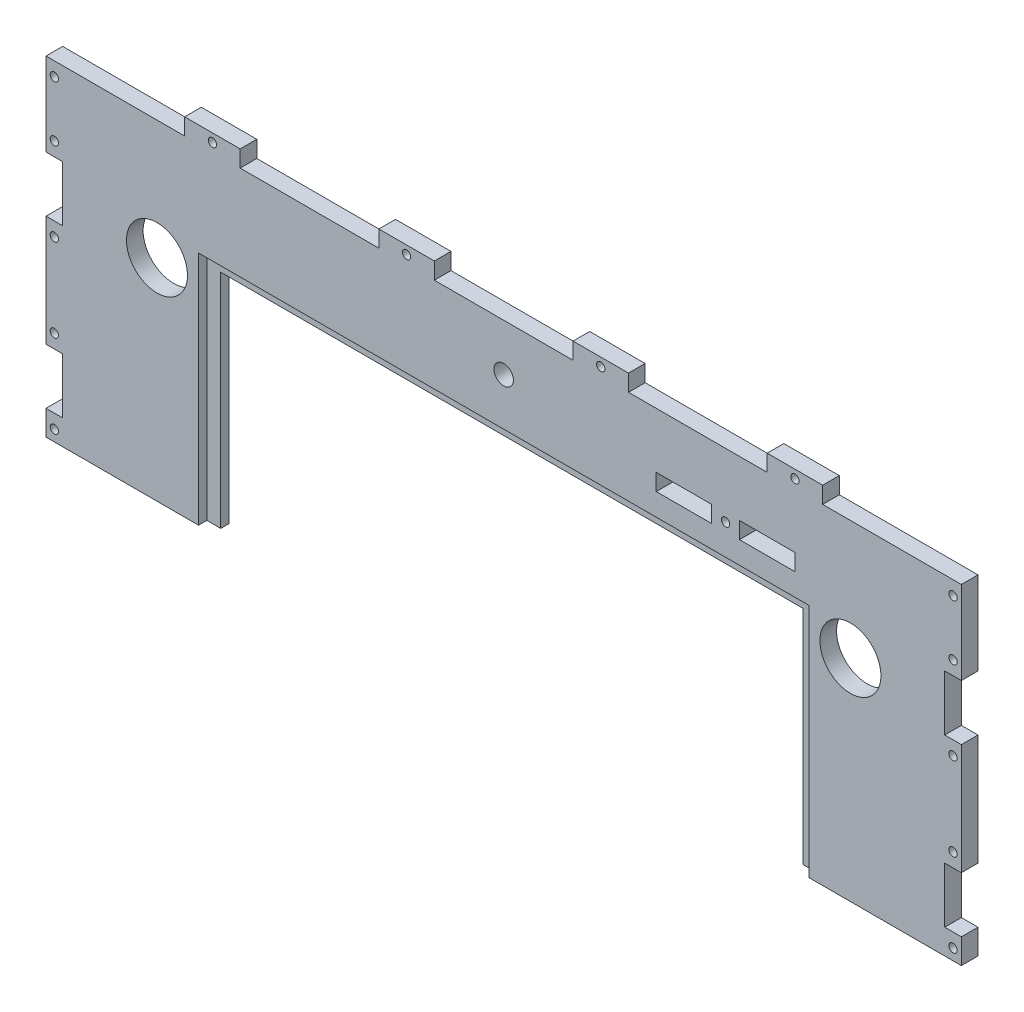
from build123d import *

# Parameters (mm, degrees)
ESQUISSE1_W                  = 330
ESQUISSE1_H                  = 238
ESQUISSE1_R                  = 11
ESQUISSE1_W_2                = 15
ESQUISSE1_H_2                = 6
ESQUISSE1_W_3                = 20
BOSS_EXTRU_1_DEPTH           = 6
ESQUISSE2_W                  = 20
ESQUISSE2_H                  = 6
BOSS_EXTRU_2_DEPTH           = 6
ESQUISSE3_W                  = 6
ESQUISSE3_H                  = 20
ESQUISSE3_W_2                = 12
ESQUISSE3_H_2                = 10
ENL_V_MAT_EXTRU_1_DEPTH      = 6
ESQUISSE4_R                  = 1.5
ENL_V_MAT_EXTRU_2_DEPTH      = 6
ESQUISSE5_W                  = 423.604058921
ESQUISSE5_H                  = 150.356061945
ENL_V_MAT_EXTRU_3_DEPTH      = 6
ESQUISSE6_W                  = 1.709615384
ESQUISSE6_H                  = 19.05
ESQUISSE6_W_2                = 1.709615385
ENL_V_MAT_EXTRU_4_DEPTH      = 6
ESQUISSE7_W                  = 1.58262541
ESQUISSE7_H                  = 1.953846154
ESQUISSE7_W_2                = 1.587980571
ESQUISSE7_H_2                = 1.936817114
ESQUISSE7_W_3                = 0.906225897
ESQUISSE7_W_4                = 1.709615385
ESQUISSE7_H_3                = 0.97063598
ESQUISSE7_W_5                = 1.216684544
ESQUISSE7_W_6                = 1.709615384
ESQUISSE7_H_4                = 3.052884616
ESQUISSE7_H_5                = 2.641773465
ESQUISSE7_W_7                = 1.710749653
ESQUISSE7_H_6                = 0.906659764
ESQUISSE7_W_8                = 1.70801118
ESQUISSE7_H_7                = 1.10546444
BOSS_EXTRU_5_DEPTH           = 6
ESQUISSE8_W                  = 210
ESQUISSE8_H                  = 80
ENL_V_MAT_EXTRU_5_DEPTH      = 6
ENL_V_MAT_EXTRU_7_DEPTH      = 1
ENL_V_MAT_EXTRU_7_DEPTH_BACK = 3
ESQUISSE12_R                 = 3.5
ENL_V_MAT_EXTRU_8_DEPTH      = 10


with BuildPart() as part:
    # Esquisse1 → Boss.-Extru.1 (new body)
    with BuildSketch(Plane.XY):
        Rectangle(ESQUISSE1_W, ESQUISSE1_H)
        with Locations((-125, 76)):
            Circle(ESQUISSE1_R, mode=Mode.SUBTRACT)
        with Locations((125, 76)):
            Circle(ESQUISSE1_R, mode=Mode.SUBTRACT)
        with Locations((-85, -58)):
            Rectangle(ESQUISSE1_W_2, ESQUISSE1_H_2, mode=Mode.SUBTRACT)
        with Locations((0, -58)):
            Rectangle(ESQUISSE1_W_2, ESQUISSE1_H_2, mode=Mode.SUBTRACT)
        with Locations((85, -58)):
            Rectangle(ESQUISSE1_W_2, ESQUISSE1_H_2, mode=Mode.SUBTRACT)
        with Locations((65, 96)):
            Rectangle(ESQUISSE1_W_3, ESQUISSE1_H_2, mode=Mode.SUBTRACT)
        with Locations((95, 96)):
            Rectangle(ESQUISSE1_W_3, ESQUISSE1_H_2, mode=Mode.SUBTRACT)
    extrude(amount=BOSS_EXTRU_1_DEPTH)

    # Esquisse2 → Boss.-Extru.2 (add)
    with BuildSketch(Plane.XY.offset(6)):
        with Locations((-105, 122)):
            Rectangle(ESQUISSE2_W, ESQUISSE2_H)
        with Locations((-35, 122)):
            Rectangle(ESQUISSE2_W, ESQUISSE2_H)
        with Locations((35, 122)):
            Rectangle(ESQUISSE2_W, ESQUISSE2_H)
        with Locations((105, 122)):
            Rectangle(ESQUISSE2_W, ESQUISSE2_H)
        with Locations((105, -122)):
            Rectangle(ESQUISSE2_W, ESQUISSE2_H)
        with Locations((35, -122)):
            Rectangle(ESQUISSE2_W, ESQUISSE2_H)
        with Locations((-35, -122)):
            Rectangle(ESQUISSE2_W, ESQUISSE2_H)
        with Locations((-105, -122)):
            Rectangle(ESQUISSE2_W, ESQUISSE2_H)
    extrude(amount=-BOSS_EXTRU_2_DEPTH)

    # Esquisse3 → Enlèv. mat.-Extru.1 (cut)
    with BuildSketch(Plane.XY.offset(6)):
        with Locations((-162, 79)):
            Rectangle(ESQUISSE3_W, ESQUISSE3_H)
        with Locations((-162, 19)):
            Rectangle(ESQUISSE3_W, ESQUISSE3_H)
        with Locations((-162, -19)):
            Rectangle(ESQUISSE3_W, ESQUISSE3_H)
        with Locations((-162, -79)):
            Rectangle(ESQUISSE3_W, ESQUISSE3_H)
        with Locations((162, -79)):
            Rectangle(ESQUISSE3_W, ESQUISSE3_H)
        with Locations((162, -19)):
            Rectangle(ESQUISSE3_W, ESQUISSE3_H)
        with Locations((162, 19)):
            Rectangle(ESQUISSE3_W, ESQUISSE3_H)
        with Locations((162, 79)):
            Rectangle(ESQUISSE3_W, ESQUISSE3_H)
        with Locations((159, -114)):
            Rectangle(ESQUISSE3_W_2, ESQUISSE3_H_2)
        with Locations((-159, -114)):
            Rectangle(ESQUISSE3_W_2, ESQUISSE3_H_2)
    extrude(amount=-ENL_V_MAT_EXTRU_1_DEPTH, mode=Mode.SUBTRACT)

    # Esquisse4 → Enlèv. mat.-Extru.2 (cut)
    with BuildSketch(Plane.XY.offset(6)):
        with Locations((-162, 114)):
            Circle(ESQUISSE4_R)
        with Locations((-162, 94)):
            Circle(ESQUISSE4_R)
        with Locations((-162, 64)):
            Circle(ESQUISSE4_R)
        with Locations((-162, 34)):
            Circle(ESQUISSE4_R)
        with Locations((-162, 4)):
            Circle(ESQUISSE4_R)
        with Locations((-105, 122)):
            Circle(ESQUISSE4_R)
        with Locations((-162, -4)):
            Circle(ESQUISSE4_R)
        with Locations((-162, -34)):
            Circle(ESQUISSE4_R)
        with Locations((-162, -64)):
            Circle(ESQUISSE4_R)
        with Locations((-162, -94)):
            Circle(ESQUISSE4_R)
        with Locations((-97.5, -58)):
            Circle(ESQUISSE4_R)
        with Locations((-72.5, -58)):
            Circle(ESQUISSE4_R)
        with Locations((162, -94)):
            Circle(ESQUISSE4_R)
        with Locations((162, -64)):
            Circle(ESQUISSE4_R)
        with Locations((162, -34)):
            Circle(ESQUISSE4_R)
        with Locations((162, -4)):
            Circle(ESQUISSE4_R)
        with Locations((80, 96)):
            Circle(ESQUISSE4_R)
        with Locations((162, 4)):
            Circle(ESQUISSE4_R)
        with Locations((162, 34)):
            Circle(ESQUISSE4_R)
        with Locations((162, 64)):
            Circle(ESQUISSE4_R)
        with Locations((162, 94)):
            Circle(ESQUISSE4_R)
        with Locations((162, 114)):
            Circle(ESQUISSE4_R)
        with Locations((-12.5, -58)):
            Circle(ESQUISSE4_R)
        with Locations((12.5, -58)):
            Circle(ESQUISSE4_R)
        with Locations((72.5, -58)):
            Circle(ESQUISSE4_R)
        with Locations((97.5, -58)):
            Circle(ESQUISSE4_R)
        with Locations((-35, 122)):
            Circle(ESQUISSE4_R)
        with Locations((35, 122)):
            Circle(ESQUISSE4_R)
        with Locations((105, 122)):
            Circle(ESQUISSE4_R)
    extrude(amount=-ENL_V_MAT_EXTRU_2_DEPTH, mode=Mode.SUBTRACT)

    # Esquisse5 → Enlèv. mat.-Extru.3 (cut)
    with BuildSketch(Plane.XY.offset(6)):
        with Locations((11.705214191, -75.178030973)):
            Rectangle(ESQUISSE5_W, ESQUISSE5_H)
    extrude(amount=-ENL_V_MAT_EXTRU_3_DEPTH, mode=Mode.SUBTRACT)

    # Esquisse6 → Enlèv. mat.-Extru.4 (cut)
    with BuildSketch(Plane.XY.offset(6)):
        with BuildLine():
            Line((-81.011538462, 33.174909856), (-79.401141827, 34.140384615))
            add(Edge.make_bspline(
                [(-79.401141827, 34.140384615), (-79.251363993, 33.889662749), (-78.964395442, 33.409289328), (-78.485688759, 32.760184851), (-77.989665343, 32.208485112), (-77.47265197, 31.757399576), (-76.937804452, 31.402259207), (-76.381631246, 31.15078706), (-75.80600659, 30.993945823), (-75.414263362, 30.974895352), (-75.218689904, 30.965384615)],
                knots=[0, 0, 0, 0, 0.000875761, 0.001677924, 0.002415421, 0.003097148, 0.00373115, 0.004334059, 0.004921814, 0.005507782, 0.005507782, 0.005507782, 0.005507782], degree=3))
            add(Edge.make_bspline(
                [(-75.218689904, 30.965384615), (-75.051665706, 30.970036476), (-74.720539841, 30.9792588), (-74.233065347, 31.06787288), (-73.759635824, 31.204010324), (-73.31000881, 31.398978537), (-72.890388393, 31.634863724), (-72.522414809, 31.91977649), (-72.204300964, 32.238761695), (-71.944082784, 32.594630144), (-71.744438591, 32.977356339), (-71.59099319, 33.370199731), (-71.50583929, 33.77933151), (-71.493011817, 34.054797029), (-71.486538462, 34.193810096)],
                knots=[0, 0, 0, 0, 0.000500623, 0.000992486, 0.001481559, 0.001975623, 0.002459366, 0.002921918, 0.003367162, 0.003806809, 0.004238704, 0.004658996, 0.005068388, 0.005485462, 0.005485462, 0.005485462, 0.005485462], degree=3))
            add(Edge.make_bspline(
                [(-71.486538462, 34.193810096), (-71.494562924, 34.352419578), (-71.510875484, 34.674849478), (-71.648751111, 35.150553303), (-71.865644869, 35.621320006), (-72.065738687, 35.912519751), (-72.169621394, 36.063701923)],
                knots=[0, 0, 0, 0, 0.000475055, 0.000965718, 0.001474521, 0.002023895, 0.002023895, 0.002023895, 0.002023895], degree=3))
            add(Edge.make_bspline(
                [(-72.169621394, 36.063701923), (-72.254914309, 36.17281392), (-72.433976113, 36.401880909), (-72.741810575, 36.742849977), (-73.103031854, 37.0945588), (-73.505278346, 37.470437381), (-73.963202729, 37.853003818), (-74.462462486, 38.260501159), (-75.015804347, 38.6774326), (-75.403877322, 38.957046135), (-75.604116587, 39.101322115)],
                knots=[0, 0, 0, 0, 0.000415395, 0.00087207, 0.001376677, 0.001927572, 0.002523203, 0.00316627, 0.003860812, 0.004601225, 0.004601225, 0.004601225, 0.004601225], degree=3))
            add(Edge.make_bspline(
                [(-75.604116587, 39.101322115), (-75.804544337, 39.244080571), (-76.187746934, 39.517023867), (-76.723642932, 39.922104613), (-77.202856367, 40.292457674), (-77.623257299, 40.631569511), (-77.984660819, 40.939486117), (-78.289914814, 41.213250614), (-78.531243246, 41.460266853), (-78.665440049, 41.62051187), (-78.725691106, 41.692457933)],
                knots=[0, 0, 0, 0, 0.000738177, 0.001411339, 0.002015128, 0.00255509, 0.003031508, 0.003439403, 0.00378484, 0.004066302, 0.004066302, 0.004066302, 0.004066302], degree=3))
            add(Edge.make_bspline(
                [(-78.725691106, 41.692457933), (-78.809905959, 41.804586433), (-78.97552577, 42.025102178), (-79.1941436, 42.369770333), (-79.379958186, 42.722594106), (-79.525621737, 43.084521597), (-79.648283157, 43.45047171), (-79.730785608, 43.825219204), (-79.782445925, 44.207082542), (-79.787736309, 44.464058881), (-79.790384615, 44.592698317)],
                knots=[0, 0, 0, 0, 0.000420569, 0.000827105, 0.001223098, 0.001614988, 0.001996332, 0.002379618, 0.002764439, 0.003150168, 0.003150168, 0.003150168, 0.003150168], degree=3))
            add(Edge.make_bspline(
                [(-79.790384615, 44.592698317), (-79.783280549, 44.79424609), (-79.769224262, 45.193033694), (-79.650349446, 45.775587214), (-79.462718411, 46.331773285), (-79.199856235, 46.85608553), (-78.860998357, 47.334871798), (-78.468862411, 47.773639491), (-78.00180275, 48.142494203), (-77.489343472, 48.464776978), (-76.928422361, 48.717031228), (-76.340643301, 48.907318848), (-75.725072095, 49.015137808), (-75.308132177, 49.030610571), (-75.096574519, 49.038461538)],
                knots=[0, 0, 0, 0, 0.000604151, 0.001195389, 0.001775851, 0.002361222, 0.002947712, 0.003531189, 0.004120021, 0.004726782, 0.005343269, 0.00595998, 0.006576078, 0.0072107, 0.0072107, 0.0072107, 0.0072107], degree=3))
            add(Edge.make_bspline(
                [(-75.096574519, 49.038461538), (-74.872088773, 49.030718793), (-74.425658273, 49.015320944), (-73.768981828, 48.881440095), (-73.136735643, 48.659912153), (-72.628137302, 48.408513886), (-72.230086129, 48.157427181), (-71.926523112, 47.92871928), (-71.618906702, 47.665420475), (-71.304755575, 47.366829435), (-70.989392843, 47.030206404), (-70.668136624, 46.657856798), (-70.340235675, 46.252056115), (-70.129293065, 45.962362761), (-70.021153846, 45.813852163)],
                knots=[0, 0, 0, 0, 0.000672945, 0.001338273, 0.002000837, 0.002678365, 0.003035146, 0.003411415, 0.003817467, 0.004249345, 0.004710968, 0.005200635, 0.005724499, 0.006275553, 0.006275553, 0.006275553, 0.006275553], degree=3))
            Line((-70.021153846, 45.813852163), (-71.566676683, 44.642307692))
            add(Edge.make_bspline(
                [(-71.566676683, 44.642307692), (-71.659999544, 44.762533279), (-71.839717554, 44.994059648), (-72.11256519, 45.318297809), (-72.369732831, 45.614478933), (-72.623100007, 45.871736273), (-72.859285344, 46.104157885), (-73.088522388, 46.303147418), (-73.307512214, 46.470654588), (-73.583557113, 46.649417392), (-73.930363552, 46.82661779), (-74.365707956, 46.976563487), (-74.82065611, 47.066670324), (-75.130515962, 47.078584126), (-75.287379808, 47.084615385)],
                knots=[0, 0, 0, 0, 0.000456531, 0.000879173, 0.001271193, 0.001632818, 0.001962066, 0.002265056, 0.002542873, 0.002788442, 0.003250947, 0.003707127, 0.004165902, 0.004636274, 0.004636274, 0.004636274, 0.004636274], degree=3))
            add(Edge.make_bspline(
                [(-75.287379808, 47.084615385), (-75.484174594, 47.078020275), (-75.863674801, 47.065302227), (-76.402464514, 46.926400593), (-76.887390021, 46.707696467), (-77.304054696, 46.401182087), (-77.650965957, 46.038029255), (-77.901911383, 45.620132915), (-78.052951564, 45.15867441), (-78.0713826, 44.836774823), (-78.080769231, 44.672836538)],
                knots=[0, 0, 0, 0, 0.000589178, 0.001136173, 0.001656971, 0.002176017, 0.002678179, 0.00315397, 0.003627044, 0.004118018, 0.004118018, 0.004118018, 0.004118018], degree=3))
            add(Edge.make_bspline(
                [(-78.080769231, 44.672836538), (-78.078629499, 44.57077492), (-78.074346536, 44.366484791), (-78.01461228, 44.064670623), (-77.937871646, 43.763618904), (-77.816263893, 43.464683132), (-77.648377312, 43.162635263), (-77.427913426, 42.852274092), (-77.150255256, 42.530864077), (-76.937564661, 42.321818229), (-76.825270433, 42.211448317)],
                knots=[0, 0, 0, 0, 0.00030567, 0.000611839, 0.000920095, 0.001236855, 0.001576745, 0.001954713, 0.002376906, 0.002849133, 0.002849133, 0.002849133, 0.002849133], degree=3))
            add(Edge.make_bspline(
                [(-76.825270433, 42.211448317), (-76.783570677, 42.174235363), (-76.684501603, 42.0858259), (-76.503385493, 41.941087915), (-76.26421112, 41.762547112), (-75.973223996, 41.541636147), (-75.625058785, 41.285378474), (-75.2196772, 40.997050671), (-74.761598, 40.667292672), (-74.436540144, 40.43674663), (-74.264663462, 40.31484375)],
                knots=[0, 0, 0, 0, 0.000167648, 0.000398294, 0.000695191, 0.001063064, 0.001494301, 0.001992036, 0.002555426, 0.003187576, 0.003187576, 0.003187576, 0.003187576], degree=3))
            add(Edge.make_bspline(
                [(-74.264663462, 40.31484375), (-74.057911562, 40.164395779), (-73.657565164, 39.873074134), (-73.087928907, 39.435383076), (-72.571435466, 39.007314507), (-72.106271458, 38.591602102), (-71.687841428, 38.191399196), (-71.320787548, 37.801891029), (-71.001369774, 37.425868126), (-70.657494313, 36.94378025), (-70.306115324, 36.351700348), (-70.004355119, 35.626285936), (-69.814081828, 34.898051677), (-69.789199723, 34.408592753), (-69.776923077, 34.167097356)],
                knots=[0, 0, 0, 0, 0.000767075, 0.001485335, 0.002154722, 0.002779037, 0.003356594, 0.003891122, 0.004384123, 0.00483528, 0.005666491, 0.006443216, 0.007186426, 0.00791025, 0.00791025, 0.00791025, 0.00791025], degree=3))
            add(Edge.make_bspline(
                [(-69.776923077, 34.167097356), (-69.780499786, 33.996309397), (-69.787583746, 33.658050067), (-69.869013863, 33.16136172), (-69.988319469, 32.678956558), (-70.168136414, 32.216797503), (-70.387609604, 31.76642958), (-70.666100181, 31.339666579), (-70.988903437, 30.927063181), (-71.3592015, 30.539621607), (-71.764399911, 30.183951597), (-72.192664021, 29.86756342), (-72.644694792, 29.60375726), (-73.11804003, 29.388487677), (-73.612808463, 29.22012096), (-74.128833686, 29.098130915), (-74.666966312, 29.023260545), (-75.032728933, 29.015489444), (-75.218689904, 29.011538462)],
                knots=[0, 0, 0, 0, 0.000511871, 0.001013801, 0.001506197, 0.002000187, 0.002498522, 0.003006623, 0.003525739, 0.004068285, 0.004611795, 0.005141506, 0.005663141, 0.00617888, 0.006699006, 0.007228455, 0.007767608, 0.008325229, 0.008325229, 0.008325229, 0.008325229], degree=3))
            add(Edge.make_bspline(
                [(-75.218689904, 29.011538462), (-75.362573699, 29.01432075), (-75.648529222, 29.019850287), (-76.07149083, 29.068734113), (-76.485907737, 29.137897063), (-76.886579758, 29.247701643), (-77.278669098, 29.380926333), (-77.660470475, 29.544964972), (-78.032168925, 29.741545739), (-78.395847483, 29.966308659), (-78.750581205, 30.227880098), (-79.093042881, 30.532535842), (-79.434468876, 30.87187352), (-79.764781705, 31.255108157), (-80.090662676, 31.676048294), (-80.40568659, 32.138632278), (-80.716374225, 32.640340446), (-80.9113127, 32.993391841), (-81.011538462, 33.174909856)],
                knots=[0, 0, 0, 0, 0.00043149, 0.000857546, 0.001276015, 0.001690708, 0.002102228, 0.002517623, 0.002935831, 0.003362587, 0.00379916, 0.004256154, 0.004736468, 0.005242286, 0.005772779, 0.00633272, 0.006920475, 0.007542442, 0.007542442, 0.007542442, 0.007542442], degree=3))
        make_face()
        with BuildLine():
            Line((-65.869230769, 48.55), (-64.159615385, 48.55))
            Line((-64.159615385, 48.55), (-64.159615385, 37.136027644))
            add(Edge.make_bspline(
                [(-64.159615385, 37.136027644), (-64.159869805, 36.97447964), (-64.160352613, 36.667914462), (-64.157127644, 36.231569854), (-64.148095939, 35.843644041), (-64.142401842, 35.502641707), (-64.129734498, 35.21012761), (-64.1194037, 34.96451699), (-64.106120098, 34.766972831), (-64.090155559, 34.651688077), (-64.083293269, 34.602133413)],
                knots=[0, 0, 0, 0, 0.000484645, 0.000919698, 0.001309016, 0.001648735, 0.001942798, 0.002187297, 0.002386321, 0.002536367, 0.002536367, 0.002536367, 0.002536367], degree=3))
            add(Edge.make_bspline(
                [(-64.083293269, 34.602133413), (-64.055113101, 34.423353173), (-64.000340615, 34.075866319), (-63.860751044, 33.581065527), (-63.665801503, 33.135124305), (-63.434790085, 32.724127134), (-63.130356872, 32.359513618), (-62.765666201, 32.023625907), (-62.323827204, 31.729865085), (-61.832551622, 31.461255666), (-61.303041972, 31.245364289), (-60.761960651, 31.082114692), (-60.217441007, 30.982625252), (-59.852899308, 30.971105233), (-59.671875, 30.965384615)],
                knots=[0, 0, 0, 0, 0.000542706, 0.001054833, 0.001536872, 0.002000273, 0.002463973, 0.002955555, 0.003482676, 0.004051288, 0.004633103, 0.005194538, 0.005744759, 0.006287505, 0.006287505, 0.006287505, 0.006287505], degree=3))
            add(Edge.make_bspline(
                [(-59.671875, 30.965384615), (-59.51646107, 30.971229429), (-59.20653084, 30.982885298), (-58.746030125, 31.055065373), (-58.297538105, 31.185152738), (-57.858840118, 31.353009137), (-57.447626903, 31.574792454), (-57.063669026, 31.830992309), (-56.720965327, 32.13149722), (-56.408229653, 32.464057667), (-56.135896645, 32.839287149), (-55.899833717, 33.249015301), (-55.706471157, 33.699408174), (-55.610984258, 34.015934387), (-55.561929087, 34.178545673)],
                knots=[0, 0, 0, 0, 0.000466331, 0.000929968, 0.001393872, 0.001865126, 0.002336303, 0.002792484, 0.003246969, 0.003700588, 0.004159315, 0.004634539, 0.005116578, 0.005625853, 0.005625853, 0.005625853, 0.005625853], degree=3))
            add(Edge.make_bspline(
                [(-55.561929087, 34.178545673), (-55.545599833, 34.245757199), (-55.509211676, 34.395531565), (-55.475209903, 34.648740304), (-55.439795814, 34.947495271), (-55.415223655, 35.293942995), (-55.391268441, 35.686922574), (-55.376937002, 36.128481204), (-55.370312865, 36.617015519), (-55.368338848, 36.957940643), (-55.367307692, 37.136027644)],
                knots=[0, 0, 0, 0, 0.000207373, 0.000462111, 0.000765533, 0.00111002, 0.001503745, 0.001946676, 0.002435197, 0.002969466, 0.002969466, 0.002969466, 0.002969466], degree=3))
            Line((-55.367307692, 37.136027644), (-55.367307692, 48.55))
            Line((-55.367307692, 48.55), (-53.657692308, 48.55))
            Line((-53.657692308, 48.55), (-53.657692308, 37.044441106))
            add(Edge.make_bspline(
                [(-53.657692308, 37.044441106), (-53.659075449, 36.837077072), (-53.661774732, 36.432393552), (-53.685182156, 35.839386869), (-53.722503826, 35.276851356), (-53.775234705, 34.744711397), (-53.84510468, 34.244871187), (-53.922802666, 33.77294952), (-54.021751267, 33.332333946), (-54.137321636, 32.91958893), (-54.269439091, 32.526693493), (-54.440568769, 32.15381089), (-54.633379262, 31.789605372), (-54.862059016, 31.439585522), (-55.119023827, 31.102201569), (-55.409953689, 30.779499603), (-55.725226622, 30.466322794), (-56.070083654, 30.170704534), (-56.438840084, 29.899603022), (-56.830398996, 29.66121801), (-57.241752557, 29.45970375), (-57.671831487, 29.293827647), (-58.12081932, 29.169106757), (-58.588727377, 29.076169123), (-59.076620701, 29.023360904), (-59.408442616, 29.015512684), (-59.576472356, 29.011538462)],
                knots=[0, 0, 0, 0, 0.000622072, 0.001214011, 0.001780083, 0.002313205, 0.002817812, 0.003293985, 0.003747637, 0.004171705, 0.004579618, 0.004989561, 0.005401029, 0.005814896, 0.006242317, 0.006672048, 0.007117291, 0.007574667, 0.008033394, 0.008488904, 0.008947996, 0.009405817, 0.009869721, 0.010344209, 0.010835584, 0.011339671, 0.011339671, 0.011339671, 0.011339671], degree=3))
            add(Edge.make_bspline(
                [(-59.576472356, 29.011538462), (-59.759728471, 29.015809827), (-60.119276315, 29.02419023), (-60.649073509, 29.072211199), (-61.156969349, 29.162662745), (-61.648328051, 29.277833296), (-62.116460014, 29.436676209), (-62.56763719, 29.622267431), (-62.994132297, 29.850199376), (-63.402864355, 30.103800558), (-63.782910527, 30.389140375), (-64.131783536, 30.700146179), (-64.450059346, 31.031835947), (-64.73237325, 31.387800795), (-64.983402636, 31.765272229), (-65.199648512, 32.165318091), (-65.385322026, 32.587783498), (-65.481152056, 32.88144306), (-65.529597356, 33.029897837)],
                knots=[0, 0, 0, 0, 0.00054985, 0.001078804, 0.00159388, 0.002096463, 0.002591234, 0.003075293, 0.003558373, 0.00404014, 0.004517154, 0.004982061, 0.005440915, 0.005894454, 0.006343216, 0.006799141, 0.007257137, 0.007725384, 0.007725384, 0.007725384, 0.007725384], degree=3))
            add(Edge.make_bspline(
                [(-65.529597356, 33.029897837), (-65.557775888, 33.131312277), (-65.618895752, 33.351282458), (-65.68434773, 33.71533606), (-65.739370017, 34.134517255), (-65.791107412, 34.608854735), (-65.821636169, 35.138716152), (-65.848401085, 35.723871822), (-65.869419325, 36.3650293), (-65.869295378, 36.811640306), (-65.869230769, 37.044441106)],
                knots=[0, 0, 0, 0, 0.000315631, 0.000684612, 0.001108268, 0.001584059, 0.002115608, 0.002700083, 0.003341473, 0.00403983, 0.00403983, 0.00403983, 0.00403983], degree=3))
            Line((-65.869230769, 37.044441106), (-65.869230769, 48.55))
        make_face()
        with BuildLine():
            Line((-48.773076923, 29.5), (-48.773076923, 48.55))
            Line((-48.773076923, 48.55), (-44.926442308, 48.55))
            add(Edge.make_bspline(
                [(-44.926442308, 48.55), (-44.591875386, 48.547591155), (-43.945493835, 48.542937278), (-43.0114318, 48.513429421), (-42.147194464, 48.461229885), (-41.355624188, 48.38519575), (-40.634547877, 48.291834239), (-39.985984596, 48.174810609), (-39.406580789, 48.036626425), (-39.050239977, 47.918813331), (-38.881730769, 47.863100962)],
                knots=[0, 0, 0, 0, 0.001003701, 0.001939145, 0.002803238, 0.003600649, 0.004324393, 0.004983829, 0.005577107, 0.006109355, 0.006109355, 0.006109355, 0.006109355], degree=3))
            add(Edge.make_bspline(
                [(-38.881730769, 47.863100962), (-38.661323688, 47.779113835), (-38.225507627, 47.613044132), (-37.604983146, 47.299773406), (-37.020826527, 46.944827809), (-36.469905182, 46.547739471), (-35.964803541, 46.097264945), (-35.485789132, 45.612539951), (-35.052457563, 45.075937699), (-34.655628124, 44.498586693), (-34.29783832, 43.887288237), (-33.986838047, 43.243207146), (-33.72855274, 42.569614342), (-33.514141035, 41.868383036), (-33.345159602, 41.137971323), (-33.229869374, 40.377528709), (-33.153827272, 39.59006055), (-33.146185221, 39.055710968), (-33.142307692, 38.784585337)],
                knots=[0, 0, 0, 0, 0.000707216, 0.001398395, 0.002081659, 0.00275642, 0.003432398, 0.004109744, 0.004798717, 0.005498398, 0.006209843, 0.006921575, 0.007641596, 0.00837191, 0.009119876, 0.00988844, 0.010677895, 0.011491048, 0.011491048, 0.011491048, 0.011491048], degree=3))
            add(Edge.make_bspline(
                [(-33.142307692, 38.784585337), (-33.145731072, 38.549120596), (-33.152477201, 38.08511273), (-33.213052477, 37.401267284), (-33.301097876, 36.737709131), (-33.437409867, 36.097598107), (-33.602886405, 35.47532595), (-33.814962714, 34.877524734), (-34.057907343, 34.298710572), (-34.341207396, 33.746709738), (-34.652219792, 33.223741669), (-34.98598528, 32.730752009), (-35.342147865, 32.274775444), (-35.72410381, 31.854431142), (-36.126917238, 31.470352779), (-36.55322538, 31.119331953), (-37.00412827, 30.80823699), (-37.477606347, 30.524843158), (-37.987472136, 30.277626652), (-38.543383065, 30.068457598), (-39.147709905, 29.895121021), (-39.798969299, 29.750499431), (-40.498286514, 29.635778683), (-41.246347171, 29.558890747), (-42.042001933, 29.506895499), (-42.588351934, 29.50234313), (-42.869561298, 29.5)],
                knots=[0, 0, 0, 0, 0.000706237, 0.001391714, 0.002058223, 0.002713094, 0.0033537, 0.003988529, 0.004614381, 0.00523561, 0.005848187, 0.006438797, 0.007020499, 0.007582414, 0.008141144, 0.008688885, 0.009237237, 0.00978306, 0.010342871, 0.010934675, 0.011562654, 0.012227402, 0.012935071, 0.013687308, 0.014482607, 0.015326104, 0.015326104, 0.015326104, 0.015326104], degree=3))
            Line((-42.869561298, 29.5), (-48.773076923, 29.5))
        make_face()
        with BuildLine():
            Line((-47.063461538, 31.453846154), (-44.876832933, 31.453846154))
            add(Edge.make_bspline(
                [(-44.876832933, 31.453846154), (-44.562625658, 31.455196507), (-43.958289998, 31.457793731), (-43.089294327, 31.480584079), (-42.295293612, 31.517823767), (-41.576175111, 31.569939548), (-40.93234485, 31.638893011), (-40.362457297, 31.715772839), (-39.868380534, 31.811553249), (-39.569407455, 31.898372042), (-39.43125, 31.938491587)],
                knots=[0, 0, 0, 0, 0.000942609, 0.001812982, 0.002607649, 0.003327064, 0.003975633, 0.004549852, 0.005052029, 0.005483452, 0.005483452, 0.005483452, 0.005483452], degree=3))
            add(Edge.make_bspline(
                [(-39.43125, 31.938491587), (-39.257359629, 31.999732211), (-38.913732256, 32.120750728), (-38.419079492, 32.341500284), (-37.957759224, 32.602986406), (-37.5217318, 32.893647355), (-37.117182433, 33.22373488), (-36.739316886, 33.586071262), (-36.388895938, 33.982500538), (-36.069540062, 34.412530674), (-35.783744864, 34.873485133), (-35.536251458, 35.360832214), (-35.319345265, 35.869232138), (-35.149100354, 36.406491987), (-35.015665531, 36.967808719), (-34.921152016, 37.553221823), (-34.862289015, 38.162621971), (-34.855423134, 38.577107105), (-34.851923077, 38.788401442)],
                knots=[0, 0, 0, 0, 0.000552954, 0.0010927, 0.001622369, 0.002142047, 0.002662942, 0.003186541, 0.00371103, 0.004248343, 0.004791599, 0.005336033, 0.00588673, 0.006447905, 0.007024554, 0.007616161, 0.008225616, 0.008859377, 0.008859377, 0.008859377, 0.008859377], degree=3))
            add(Edge.make_bspline(
                [(-34.851923077, 38.788401442), (-34.854716827, 39.011196528), (-34.860205173, 39.448879446), (-34.929189634, 40.091085944), (-35.029999815, 40.708744914), (-35.175779591, 41.301897663), (-35.361549089, 41.871701408), (-35.593385639, 42.415004742), (-35.858271096, 42.937545529), (-36.173430686, 43.427263148), (-36.518592701, 43.890412785), (-36.901649445, 44.314710254), (-37.316515112, 44.701122088), (-37.758664792, 45.055666061), (-38.240559575, 45.364078354), (-38.750847521, 45.639958718), (-39.297014674, 45.87408807), (-39.676995204, 45.998614451), (-39.870102163, 46.061899038)],
                knots=[0, 0, 0, 0, 0.000668091, 0.001312471, 0.001935443, 0.002544456, 0.003143013, 0.003731288, 0.00431499, 0.004898305, 0.005476064, 0.006046199, 0.006610479, 0.007175469, 0.007743877, 0.008324376, 0.008914147, 0.00952359, 0.00952359, 0.00952359, 0.00952359], degree=3))
            add(Edge.make_bspline(
                [(-39.870102163, 46.061899038), (-40.02985626, 46.106075596), (-40.369537302, 46.200007078), (-40.923834956, 46.302470891), (-41.54766884, 46.392846807), (-42.243808642, 46.469362707), (-43.011460827, 46.524266556), (-43.851215786, 46.56547614), (-44.763436491, 46.593270811), (-45.395801425, 46.595168774), (-45.724008413, 46.596153846)],
                knots=[0, 0, 0, 0, 0.000497047, 0.001056858, 0.001689365, 0.002388077, 0.003157248, 0.00399784, 0.00491028, 0.005894865, 0.005894865, 0.005894865, 0.005894865], degree=3))
            Line((-45.724008413, 46.596153846), (-47.063461538, 46.596153846))
            Line((-47.063461538, 46.596153846), (-47.063461538, 31.453846154))
        make_face(mode=Mode.SUBTRACT)
        with BuildLine():
            Line((-29.234615385, 48.55), (-25.422325721, 48.55))
            add(Edge.make_bspline(
                [(-25.422325721, 48.55), (-25.167920436, 48.549153168), (-24.679434107, 48.547527156), (-23.979628164, 48.538460646), (-23.343754965, 48.51247451), (-22.772146982, 48.490112077), (-22.264814703, 48.449334511), (-21.820202449, 48.410360132), (-21.440357981, 48.359340635), (-21.210419848, 48.311958262), (-21.106310096, 48.290504808)],
                knots=[0, 0, 0, 0, 0.000763231, 0.001465487, 0.002099375, 0.002672414, 0.003181388, 0.003626042, 0.004011375, 0.004330196, 0.004330196, 0.004330196, 0.004330196], degree=3))
            add(Edge.make_bspline(
                [(-21.106310096, 48.290504808), (-20.966936899, 48.256069128), (-20.691163714, 48.187932374), (-20.294106925, 48.043916547), (-19.915750391, 47.877258304), (-19.557665776, 47.681512912), (-19.221646684, 47.455227326), (-18.904228449, 47.202307973), (-18.603970713, 46.924138753), (-18.333016411, 46.613706259), (-18.077533858, 46.288024685), (-17.86205862, 45.93585138), (-17.676313066, 45.567579351), (-17.528427824, 45.179463263), (-17.409349139, 44.775267048), (-17.325386322, 44.351329454), (-17.27503343, 43.909581861), (-17.269907044, 43.608276672), (-17.267307692, 43.455498798)],
                knots=[0, 0, 0, 0, 0.000430426, 0.000851669, 0.001265096, 0.001669855, 0.002074164, 0.002478834, 0.002886515, 0.003300082, 0.003713774, 0.004126778, 0.004536365, 0.004949528, 0.005370979, 0.005799064, 0.006244503, 0.00670269, 0.00670269, 0.00670269, 0.00670269], degree=3))
            add(Edge.make_bspline(
                [(-17.267307692, 43.455498798), (-17.275303239, 43.201670586), (-17.290904622, 42.706386001), (-17.436365543, 41.987597489), (-17.674634887, 41.317095648), (-18.002965931, 40.695724719), (-18.421083363, 40.135596777), (-18.923594012, 39.643614442), (-19.510778211, 39.231917204), (-20.057400631, 38.946424081), (-20.540259347, 38.763582678), (-20.937769235, 38.634933354), (-21.371385212, 38.535536085), (-21.836952705, 38.446490225), (-22.336409173, 38.379261717), (-22.86855753, 38.330022396), (-23.433777298, 38.299248217), (-23.822065661, 38.294665304), (-24.021814904, 38.292307692)],
                knots=[0, 0, 0, 0, 0.000760784, 0.001484488, 0.002189383, 0.002889303, 0.0035846, 0.004278134, 0.004989692, 0.005728727, 0.006121341, 0.006537716, 0.006981075, 0.007454841, 0.007959448, 0.008492202, 0.00905781, 0.009657048, 0.009657048, 0.009657048, 0.009657048], degree=3))
            Line((-24.021814904, 38.292307692), (-17.023076923, 29.5))
            Line((-17.023076923, 29.5), (-19.137199519, 29.5))
            Line((-19.137199519, 29.5), (-26.1359375, 38.292307692))
            Line((-26.1359375, 38.292307692), (-27.525, 38.292307692))
            Line((-27.525, 38.292307692), (-27.525, 29.5))
            Line((-27.525, 29.5), (-29.234615385, 29.5))
            Line((-29.234615385, 29.5), (-29.234615385, 48.55))
        make_face()
        with BuildLine():
            Line((-27.525, 46.596153846), (-27.525, 40.246153846))
            Line((-27.525, 40.246153846), (-24.037079327, 40.219441106))
            add(Edge.make_bspline(
                [(-24.037079327, 40.219441106), (-23.874228829, 40.219369061), (-23.558578183, 40.219229416), (-23.10191885, 40.24096697), (-22.676722242, 40.265695602), (-22.28461472, 40.303519897), (-21.925421117, 40.352266516), (-21.599320968, 40.413242759), (-21.305781957, 40.484283271), (-20.963434197, 40.594237835), (-20.581146791, 40.76844202), (-20.165685559, 41.021891377), (-19.811887121, 41.340674726), (-19.512977042, 41.705201679), (-19.272786851, 42.105993262), (-19.103448384, 42.538245214), (-18.99599309, 42.991045198), (-18.98331915, 43.302257471), (-18.976923077, 43.459314904)],
                knots=[0, 0, 0, 0, 0.000488476, 0.000946806, 0.001371236, 0.001766143, 0.002128271, 0.002458336, 0.00276099, 0.003033728, 0.00353589, 0.004017658, 0.004487953, 0.004957024, 0.005427582, 0.005883236, 0.006345173, 0.006815809, 0.006815809, 0.006815809, 0.006815809], degree=3))
            add(Edge.make_bspline(
                [(-18.976923077, 43.459314904), (-18.98346605, 43.612512684), (-18.996431836, 43.916094783), (-19.102288705, 44.360536237), (-19.281300909, 44.780000637), (-19.522540518, 45.17278162), (-19.816450204, 45.529319982), (-20.161080014, 45.83437663), (-20.547006861, 46.086105859), (-20.907711527, 46.24696613), (-21.230114883, 46.345589903), (-21.510039176, 46.414992666), (-21.826331647, 46.470751846), (-22.180528072, 46.515427149), (-22.571116377, 46.553826203), (-23.000071492, 46.579689455), (-23.464547396, 46.595004916), (-23.786475693, 46.595761957), (-23.953125, 46.596153846)],
                knots=[0, 0, 0, 0, 0.000459219, 0.000910004, 0.001361483, 0.001822238, 0.002288365, 0.002742498, 0.00319764, 0.0036657, 0.003921579, 0.004208498, 0.004530366, 0.004884421, 0.005279328, 0.005707566, 0.006173381, 0.006673306, 0.006673306, 0.006673306, 0.006673306], degree=3))
            Line((-23.953125, 46.596153846), (-27.525, 46.596153846))
        make_face(mode=Mode.SUBTRACT)
        with Locations((-12.260576923, 39.025)):
            Rectangle(ESQUISSE6_W, ESQUISSE6_H)
        Polygon((1.294230769, 48.55), (10.086538462, 29.5), (8.228094952, 29.5), (5.411808894, 35.605769231), (-3.224038462, 35.605769231), (-6.12046274, 29.5), (-7.986538462, 29.5), (1.05, 48.55), align=None)
        Polygon((1.153034856, 44.836929087), (-2.29672476, 37.559615385), (4.511207933, 37.559615385), align=None, mode=Mode.SUBTRACT)
        with BuildLine():
            Line((13.505769231, 48.55), (17.22265625, 48.55))
            add(Edge.make_bspline(
                [(17.22265625, 48.55), (17.404602681, 48.549043416), (17.757260148, 48.547189317), (18.270083109, 48.518433989), (18.750408779, 48.479225443), (19.198376454, 48.417013082), (19.613779134, 48.341946409), (19.997868703, 48.25104081), (20.349423783, 48.142038813), (20.769137391, 47.968704053), (21.247676988, 47.711130809), (21.76582824, 47.330519618), (22.208899886, 46.86497864), (22.590913984, 46.33983733), (22.894631506, 45.762155487), (23.114355825, 45.145701902), (23.253463689, 44.49842785), (23.267769881, 44.054055696), (23.275, 43.829477163)],
                knots=[0, 0, 0, 0, 0.000545756, 0.001057812, 0.00154047, 0.00199111, 0.00241401, 0.002806457, 0.003174568, 0.003516849, 0.004167392, 0.004800106, 0.005437019, 0.006087371, 0.006742853, 0.007387425, 0.008046032, 0.008718977, 0.008718977, 0.008718977, 0.008718977], degree=3))
            add(Edge.make_bspline(
                [(23.275, 43.829477163), (23.269049768, 43.619096825), (23.257357002, 43.205679619), (23.145545697, 42.601010253), (22.970499773, 42.025421476), (22.727175489, 41.481013921), (22.410934623, 40.980088113), (22.036148632, 40.518603136), (21.583973464, 40.116098097), (21.245192401, 39.891074585), (21.073106971, 39.776772837)],
                knots=[0, 0, 0, 0, 0.000630593, 0.001239176, 0.001837903, 0.002432285, 0.003022056, 0.003610343, 0.004210261, 0.004829576, 0.004829576, 0.004829576, 0.004829576], degree=3))
            add(Edge.make_bspline(
                [(21.073106971, 39.776772837), (21.289517298, 39.693687628), (21.703563864, 39.534725042), (22.273354874, 39.253680588), (22.76427253, 38.947998245), (23.180091282, 38.614177746), (23.535714804, 38.254356933), (23.846245814, 37.863259811), (24.111211579, 37.435784572), (24.338249063, 36.976388187), (24.515407293, 36.489761552), (24.648081858, 35.980469185), (24.724104688, 35.45033732), (24.734923136, 35.089555469), (24.740384615, 34.907421875)],
                knots=[0, 0, 0, 0, 0.00069517, 0.001330033, 0.001902818, 0.002426682, 0.002925892, 0.003417578, 0.003921593, 0.004431882, 0.004952231, 0.005472399, 0.0060083, 0.006554657, 0.006554657, 0.006554657, 0.006554657], degree=3))
            add(Edge.make_bspline(
                [(24.740384615, 34.907421875), (24.735067782, 34.721456471), (24.724606763, 34.355564329), (24.647427203, 33.818054239), (24.516749063, 33.304384887), (24.336747538, 32.811233821), (24.101821226, 32.339555089), (23.81591902, 31.888814324), (23.475024366, 31.463540324), (23.09368218, 31.059007461), (22.662269645, 30.695273362), (22.196819607, 30.371337873), (21.691470352, 30.104931449), (21.154521642, 29.881142817), (20.57995015, 29.710197923), (19.970335958, 29.590604342), (19.32620483, 29.510022641), (18.884191756, 29.503397568), (18.657512019, 29.5)],
                knots=[0, 0, 0, 0, 0.000557791, 0.00109747, 0.001625032, 0.002145382, 0.002669315, 0.003202874, 0.00374343, 0.00430216, 0.004867987, 0.005433235, 0.006000039, 0.006578327, 0.007175946, 0.007794874, 0.008440506, 0.009120159, 0.009120159, 0.009120159, 0.009120159], degree=3))
            Line((18.657512019, 29.5), (13.505769231, 29.5))
            Line((13.505769231, 29.5), (13.505769231, 48.55))
        make_face()
        with BuildLine():
            Line((15.215384615, 46.596153846), (15.215384615, 40.490384615))
            Line((15.215384615, 40.490384615), (16.364032452, 40.490384615))
            add(Edge.make_bspline(
                [(16.364032452, 40.490384615), (16.531938038, 40.492561339), (16.856365848, 40.496767213), (17.326192713, 40.50881507), (17.762301741, 40.542550135), (18.163940147, 40.576275504), (18.530475449, 40.631110046), (18.861095609, 40.696381458), (19.160989401, 40.765412698), (19.50682607, 40.882812334), (19.899108833, 41.056317966), (20.317300443, 41.325586103), (20.685969484, 41.646302939), (20.997285606, 42.016368031), (21.252073753, 42.423853986), (21.429041259, 42.862259149), (21.549041478, 43.320657296), (21.559881098, 43.635353787), (21.565384615, 43.795132212)],
                knots=[0, 0, 0, 0, 0.000503784, 0.000973413, 0.001409519, 0.001815822, 0.002182268, 0.002520548, 0.002826908, 0.003104462, 0.003615151, 0.004109495, 0.004590899, 0.005075605, 0.005555358, 0.006025916, 0.006489616, 0.006967864, 0.006967864, 0.006967864, 0.006967864], degree=3))
            add(Edge.make_bspline(
                [(21.565384615, 43.795132212), (21.562520692, 43.900863911), (21.556902793, 44.108268185), (21.510892675, 44.410615384), (21.432692019, 44.694970665), (21.332247938, 44.965230894), (21.191883789, 45.212945393), (21.026619796, 45.446679073), (20.826944824, 45.658472175), (20.599665737, 45.856426159), (20.338361661, 46.031928517), (20.043188487, 46.185638957), (19.710152702, 46.309413755), (19.34486702, 46.417814528), (18.941708672, 46.493950813), (18.505330031, 46.557378537), (18.032156775, 46.589669604), (17.704795574, 46.593944222), (17.535576923, 46.596153846)],
                knots=[0, 0, 0, 0, 0.000317104, 0.000622035, 0.000914559, 0.001200868, 0.001484418, 0.001766113, 0.002057739, 0.002355347, 0.002668639, 0.002999762, 0.003351279, 0.00373289, 0.004141516, 0.004580816, 0.005055258, 0.005562929, 0.005562929, 0.005562929, 0.005562929], degree=3))
            Line((17.535576923, 46.596153846), (15.215384615, 46.596153846))
        make_face(mode=Mode.SUBTRACT)
        with BuildLine():
            Line((15.215384615, 38.536538462), (15.215384615, 31.453846154))
            Line((15.215384615, 31.453846154), (17.650060096, 31.453846154))
            add(Edge.make_bspline(
                [(17.650060096, 31.453846154), (17.824334536, 31.455934836), (18.160225543, 31.459960496), (18.64519081, 31.473102571), (19.094678846, 31.502996243), (19.506638557, 31.550054368), (19.885518306, 31.601099927), (20.226772947, 31.669741327), (20.533168757, 31.748384955), (20.888447489, 31.869946664), (21.288516584, 32.058794599), (21.719649959, 32.34353346), (22.102969804, 32.682750321), (22.428481286, 33.075348582), (22.695251981, 33.50223909), (22.889319529, 33.954787352), (23.009012621, 34.425515723), (23.023502428, 34.746463115), (23.030769231, 34.907421875)],
                knots=[0, 0, 0, 0, 0.000522862, 0.001007748, 0.001455275, 0.001873744, 0.002251519, 0.00260177, 0.002917401, 0.003199793, 0.003727272, 0.004239541, 0.004745013, 0.005257068, 0.005764323, 0.006249869, 0.006729304, 0.007211645, 0.007211645, 0.007211645, 0.007211645], degree=3))
            add(Edge.make_bspline(
                [(23.030769231, 34.907421875), (23.029266434, 35.008078486), (23.026285082, 35.207768106), (22.981323735, 35.501224208), (22.915933958, 35.785482176), (22.831398582, 36.061313877), (22.708284054, 36.323732397), (22.564557002, 36.577927757), (22.396038516, 36.824235981), (22.133452413, 37.135634103), (21.751516326, 37.494410988), (21.208826591, 37.845679393), (20.591757369, 38.128968171), (20.144204872, 38.249252464), (19.913010817, 38.311388221)],
                knots=[0, 0, 0, 0, 0.00030169, 0.000598513, 0.000888261, 0.001176699, 0.001461887, 0.001755827, 0.002052208, 0.00235563, 0.002976636, 0.003615922, 0.004287047, 0.005004191, 0.005004191, 0.005004191, 0.005004191], degree=3))
            add(Edge.make_bspline(
                [(19.913010817, 38.311388221), (19.820323881, 38.33019375), (19.619359486, 38.370968014), (19.291658227, 38.414008514), (18.917538712, 38.452353768), (18.496137051, 38.480717355), (18.026920087, 38.510035542), (17.508885716, 38.521437354), (16.944149475, 38.53504047), (16.552305276, 38.536026358), (16.348768029, 38.536538462)],
                knots=[0, 0, 0, 0, 0.000283652, 0.000615017, 0.000990937, 0.001411818, 0.001881958, 0.002401173, 0.002966073, 0.003576662, 0.003576662, 0.003576662, 0.003576662], degree=3))
            Line((16.348768029, 38.536538462), (15.215384615, 38.536538462))
        make_face(mode=Mode.SUBTRACT)
        with BuildLine():
            add(Edge.make_bspline(
                [(37.5625, 49.038461538), (37.915241262, 49.029527201), (38.608054204, 49.011979424), (39.626276147, 48.877654589), (40.598343737, 48.645269681), (41.532175493, 48.335772591), (42.416601551, 47.922908007), (43.258278951, 47.423878843), (44.055205079, 46.833456974), (44.796638598, 46.156206468), (45.475128571, 45.419333669), (46.07289518, 44.632961044), (46.573868236, 43.801843278), (46.985270878, 42.928477899), (47.308024739, 42.014840074), (47.530741248, 41.056059002), (47.673007465, 40.058346874), (47.689639625, 39.37784351), (47.698076923, 39.032632212)],
                knots=[0, 0, 0, 0, 0.001058053, 0.002078103, 0.00307407, 0.004052758, 0.005024255, 0.005996134, 0.006983761, 0.007994128, 0.009004251, 0.009984998, 0.010952288, 0.011909956, 0.012876697, 0.013853217, 0.014858651, 0.015893829, 0.015893829, 0.015893829, 0.015893829], degree=3))
            add(Edge.make_bspline(
                [(47.698076923, 39.032632212), (47.689640862, 38.689963825), (47.673012408, 38.014524737), (47.53057949, 37.02314399), (47.30719919, 36.070150342), (46.988268084, 35.157134718), (46.578826551, 34.283133978), (46.074517691, 33.450447843), (45.480477673, 32.658803331), (44.804437526, 31.916872967), (44.067468998, 31.236529591), (43.277001403, 30.643699711), (42.450812047, 30.133572689), (41.578269207, 29.726535835), (40.670944721, 29.401205811), (39.720718077, 29.179395068), (38.732041833, 29.036318447), (38.057829655, 29.019889096), (37.715144231, 29.011538462)],
                knots=[0, 0, 0, 0, 0.001027553, 0.002025427, 0.002998234, 0.003960113, 0.004921233, 0.005888524, 0.006875369, 0.007885737, 0.008895859, 0.009879653, 0.010845663, 0.01180333, 0.012762874, 0.01373197, 0.014726064, 0.015753617, 0.015753617, 0.015753617, 0.015753617], degree=3))
            add(Edge.make_bspline(
                [(37.715144231, 29.011538462), (37.369934723, 29.019971553), (36.689434891, 29.036595421), (35.690469027, 29.179097067), (34.731014449, 29.401934735), (33.813814909, 29.720393237), (32.938358935, 30.131967022), (32.102934342, 30.633822285), (31.310894412, 31.229309725), (30.568805764, 31.905130652), (29.889813699, 32.6408501), (29.297851954, 33.429162259), (28.795883838, 34.254601245), (28.385691985, 35.119457769), (28.060946856, 36.019550907), (27.839396346, 36.960884763), (27.696053521, 37.938092645), (27.679535286, 38.603443277), (27.671153846, 38.941045673)],
                knots=[0, 0, 0, 0, 0.001035178, 0.002040611, 0.003020846, 0.003986328, 0.004947449, 0.005918008, 0.006904854, 0.007915221, 0.008925344, 0.009903794, 0.010867819, 0.011818589, 0.012770942, 0.013732616, 0.014715373, 0.015727677, 0.015727677, 0.015727677, 0.015727677], degree=3))
            add(Edge.make_bspline(
                [(27.671153846, 38.941045673), (27.674063791, 39.167646344), (27.67984697, 39.617989016), (27.749470325, 40.286734368), (27.850499013, 40.944724948), (27.995289422, 41.590089679), (28.184655496, 42.221248753), (28.408095816, 42.842555048), (28.680999832, 43.447712173), (28.989504502, 44.039586919), (29.333829485, 44.608952807), (29.714153207, 45.147140252), (30.117117141, 45.658665392), (30.558877898, 46.130272656), (31.024875978, 46.575681557), (31.522670865, 46.988047202), (32.049225081, 47.371088007), (32.606804319, 47.716275863), (33.181669501, 48.028473439), (33.774270249, 48.296380942), (34.376558159, 48.52632022), (34.991354172, 48.71268814), (35.617025688, 48.85981965), (36.254938259, 48.960008247), (36.904583679, 49.029809177), (37.342251, 49.035565009), (37.5625, 49.038461538)],
                knots=[0, 0, 0, 0, 0.000679535, 0.001350497, 0.002014905, 0.002675929, 0.003332765, 0.003990697, 0.004655204, 0.005322597, 0.005992114, 0.006649571, 0.007298589, 0.007943963, 0.008586385, 0.00923134, 0.009881692, 0.010538207, 0.011197278, 0.011842821, 0.012487777, 0.013129994, 0.013768699, 0.014414264, 0.015066238, 0.0157267, 0.0157267, 0.0157267, 0.0157267], degree=3))
        make_face()
        with BuildLine():
            add(Edge.make_bspline(
                [(37.646454327, 47.084615385), (37.465671821, 47.082411625), (37.105835104, 47.078025173), (36.570886414, 47.02024535), (36.042973174, 46.937895526), (35.52198636, 46.820430391), (35.010105842, 46.660388333), (34.502560278, 46.476197104), (34.003977941, 46.251836596), (33.516004801, 45.99834802), (33.042938463, 45.717774608), (32.596555045, 45.407685419), (32.17569894, 45.075352431), (31.781400589, 44.720000059), (31.41481778, 44.339818655), (31.068735334, 43.940571824), (30.757025182, 43.51084796), (30.471353686, 43.062299888), (30.215714441, 42.595511853), (29.988391582, 42.115398174), (29.802441762, 41.618042479), (29.650790828, 41.108840564), (29.525061858, 40.588598891), (29.4454115, 40.053370914), (29.3869968, 39.50584609), (29.38286107, 39.13583057), (29.380769231, 38.948677885)],
                knots=[0, 0, 0, 0, 0.000542102, 0.001079021, 0.001612294, 0.002144596, 0.002679355, 0.003220247, 0.003763476, 0.004318191, 0.004869245, 0.005412287, 0.005947481, 0.006477054, 0.007003304, 0.007531045, 0.008060756, 0.008594315, 0.009125467, 0.009656399, 0.010186564, 0.010716563, 0.011249726, 0.011790537, 0.012338849, 0.012900025, 0.012900025, 0.012900025, 0.012900025], degree=3))
            add(Edge.make_bspline(
                [(29.380769231, 38.948677885), (29.387708122, 38.67347494), (29.401359069, 38.132065611), (29.520870986, 37.338670428), (29.704959161, 36.576189898), (29.976325684, 35.848796077), (30.315691172, 35.150236481), (30.734937532, 34.486708082), (31.231647698, 33.858031552), (31.795873464, 33.268595874), (32.412672767, 32.730592282), (33.067626626, 32.258351444), (33.753718404, 31.858789941), (34.472737264, 31.533279476), (35.220844584, 31.275343903), (36.002860969, 31.098567353), (36.813577042, 30.982223803), (37.366193893, 30.971050946), (37.646454327, 30.965384615)],
                knots=[0, 0, 0, 0, 0.000825162, 0.001623348, 0.002401731, 0.003174434, 0.00394756, 0.004727858, 0.005524108, 0.006347335, 0.007172294, 0.007976126, 0.008766133, 0.009550007, 0.010340456, 0.011135618, 0.011952166, 0.012792412, 0.012792412, 0.012792412, 0.012792412], degree=3))
            add(Edge.make_bspline(
                [(37.646454327, 30.965384615), (37.8348289, 30.967972718), (38.208432255, 30.973105702), (38.764123598, 31.024805643), (39.309803836, 31.107710532), (39.844707588, 31.227075958), (40.368227776, 31.376467181), (40.88254949, 31.553946386), (41.38219447, 31.775368366), (41.873465873, 32.020013646), (42.343708274, 32.298906503), (42.792610814, 32.598471289), (43.208858648, 32.930314782), (43.602862022, 33.280387447), (43.970949872, 33.655747819), (44.310633058, 34.055907884), (44.620767777, 34.483393461), (44.906330796, 34.931261169), (45.161074269, 35.399326488), (45.38302908, 35.881180878), (45.571330796, 36.37563783), (45.723341658, 36.883410526), (45.842461099, 37.403534575), (45.924538949, 37.9367064), (45.981952594, 38.481859393), (45.986280085, 38.850579523), (45.988461538, 39.036448317)],
                knots=[0, 0, 0, 0, 0.00056499, 0.001120545, 0.001672668, 0.002219864, 0.002763441, 0.003305341, 0.003850524, 0.004401763, 0.004950871, 0.005489605, 0.006019439, 0.006546463, 0.007069979, 0.007595245, 0.008119623, 0.008653182, 0.009187682, 0.009717008, 0.010243603, 0.010773602, 0.011305904, 0.011842946, 0.012391258, 0.012948618, 0.012948618, 0.012948618, 0.012948618], degree=3))
            add(Edge.make_bspline(
                [(45.988461538, 39.036448317), (45.986278338, 39.221045562), (45.981947557, 39.587228201), (45.924566374, 40.128579226), (45.842374385, 40.657914563), (45.723923074, 41.173156119), (45.571250094, 41.674435234), (45.382996196, 42.161281104), (45.161007638, 42.635507423), (44.906237159, 43.095942097), (44.619856748, 43.537764599), (44.306923796, 43.960143445), (43.962035258, 44.355146508), (43.595045037, 44.732525343), (43.196786361, 45.084231285), (42.769063275, 45.410381004), (42.3170684, 45.71884554), (41.838493018, 45.997114669), (41.344586642, 46.254094993), (40.83778067, 46.474264025), (40.323816571, 46.66134656), (39.804001331, 46.820914613), (39.273959692, 46.937435463), (38.737273138, 47.020319563), (38.194684188, 47.078005063), (37.82977752, 47.082404952), (37.646454327, 47.084615385)],
                knots=[0, 0, 0, 0, 0.000553546, 0.00109806, 0.001631333, 0.002159915, 0.00268261, 0.003202077, 0.00372448, 0.00425229, 0.004779424, 0.005302996, 0.005827846, 0.006351362, 0.006881238, 0.007420106, 0.007964139, 0.008521761, 0.009079865, 0.009633569, 0.010178043, 0.010720105, 0.011263575, 0.011804386, 0.012348901, 0.012898632, 0.012898632, 0.012898632, 0.012898632], degree=3))
        make_face(mode=Mode.SUBTRACT)
        Polygon((49.407692308, 46.596153846), (49.407692308, 48.55), (59.421153846, 48.55), (59.421153846, 46.596153846), (55.269230769, 46.596153846), (55.269230769, 29.5), (53.559615385, 29.5), (53.559615385, 46.596153846), align=None)
        with Locations((63.206730769, 39.025)):
            Rectangle(ESQUISSE6_W_2, ESQUISSE6_H)
        Polygon((68.946153846, 48.55), (70.655769231, 48.55), (70.655769231, 41.295582933), (78.597085337, 48.55), (81.035576923, 48.55), (71.674669471, 40.001923077), (81.768269231, 29.5), (79.490054087, 29.5), (70.655769231, 38.692998798), (70.655769231, 29.5), (68.946153846, 29.5), align=None)
    extrude(amount=-ENL_V_MAT_EXTRU_4_DEPTH, mode=Mode.SUBTRACT)

    # Esquisse7 → Boss.-Extru.5 (add)
    with BuildSketch(Plane.XY.offset(6)):
        with Locations((-45.178834531, 30.476923077)):
            Rectangle(ESQUISSE7_W, ESQUISSE7_H)
        with Locations((-44.384844246, 47.562132152)):
            Rectangle(ESQUISSE7_W_2, ESQUISSE7_H_2)
        with Locations((-25.875438669, 47.573076923)):
            Rectangle(ESQUISSE7_W_3, ESQUISSE7_H)
        with Locations((-28.379807693, 42.935835856)):
            Rectangle(ESQUISSE7_W_4, ESQUISSE7_H_3)
        with Locations((1.279551333, 36.582692308)):
            Rectangle(ESQUISSE7_W_5, ESQUISSE7_H)
        with Locations((14.360576923, 42.016826923)):
            Rectangle(ESQUISSE7_W_6, ESQUISSE7_H_4)
        with Locations((14.360576923, 34.284882499)):
            Rectangle(ESQUISSE7_W_6, ESQUISSE7_H_5)
        with Locations((28.537557324, 38.999545465)):
            Rectangle(ESQUISSE7_W_7, ESQUISSE7_H_6)
        with Locations((46.827350298, 39.034548512)):
            Rectangle(ESQUISSE7_W_8, ESQUISSE7_H_7)
    extrude(amount=-BOSS_EXTRU_5_DEPTH)

    # Esquisse8 → Enlèv. mat.-Extru.5 (cut)
    with BuildSketch(Plane.XY.offset(6)):
        with Locations((-0.004423077, 40)):
            Rectangle(ESQUISSE8_W, ESQUISSE8_H)
    extrude(amount=-ENL_V_MAT_EXTRU_5_DEPTH, mode=Mode.SUBTRACT)

    # Esquisse11 → Enlèv. mat.-Extru.7 (cut, two sides)
    with BuildSketch(Plane.XY.offset(6)) as enl_v_mat_extru_7_sk:
        Polygon((-110.004423077, -614.160351933), (-110.004423077, 0), (-110.004423077, 85), (109.995576923, 85), (109.995576923, 0), (109.995576923, -614.160351933), (109.995576923, -1842.481055798), (-110.004423077, -1842.481055798), align=None)
    extrude(amount=ENL_V_MAT_EXTRU_7_DEPTH, mode=Mode.SUBTRACT)
    extrude(enl_v_mat_extru_7_sk.sketch, amount=-ENL_V_MAT_EXTRU_7_DEPTH_BACK, mode=Mode.SUBTRACT)

    # Esquisse12 → Enlèv. mat.-Extru.8 (cut)
    with BuildSketch(Plane.XY.offset(6)):
        with Locations((0, 102)):
            Circle(ESQUISSE12_R)
    extrude(amount=-ENL_V_MAT_EXTRU_8_DEPTH, mode=Mode.SUBTRACT)


solid = part.part
